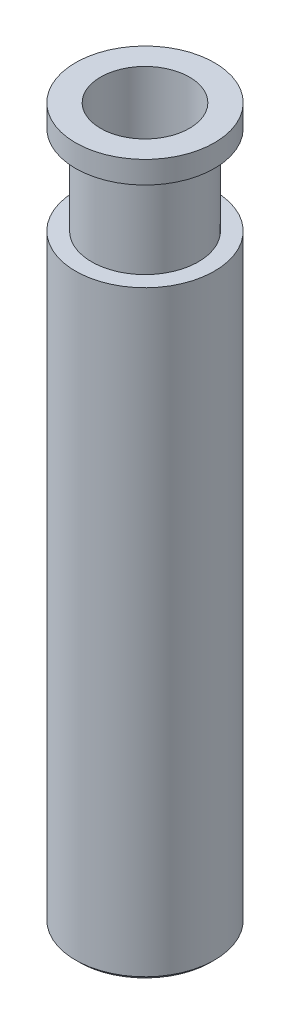
from build123d import *

# Parameters (mm, degrees)
SKETCH1_R           = 4.95935
BOSS_EXTRUDE1_DEPTH = 1.5875
SKETCH2_R           = 3.81
BOSS_EXTRUDE2_DEPTH = 6.35
SKETCH3_R           = 4.95935
BOSS_EXTRUDE4_DEPTH = 42.8625
CHAMFER1_SIZE       = 0.254
SKETCH4_R           = 3.175
CUT_EXTRUDE1_DEPTH  = 7.9375


with BuildPart() as part:
    # Sketch1 → Boss-Extrude1 (new body)
    with BuildSketch(Plane(origin=(0, 0, 0), x_dir=(1, 0, 0), z_dir=(0, 1, 0))):
        Circle(SKETCH1_R)
    extrude(amount=-BOSS_EXTRUDE1_DEPTH)

    # Sketch2 → Boss-Extrude2 (add)
    with BuildSketch(Plane.XZ.offset(1.5875)):
        Circle(SKETCH2_R)
    extrude(amount=BOSS_EXTRUDE2_DEPTH)

    # Sketch3 → Boss-Extrude4 (add)
    with BuildSketch(Plane.XZ.offset(7.9375)):
        Circle(SKETCH3_R)
    extrude(amount=BOSS_EXTRUDE4_DEPTH)

    # Chamfer1
    chamfer1_edges = [part.edges().sort_by_distance(p)[0] for p in [
        (-4.95935, -50.8, 0),
    ]]
    chamfer(chamfer1_edges, length=CHAMFER1_SIZE)

    # Sketch4 → Cut-Extrude1 (cut)
    with BuildSketch(Plane(origin=(0, 0, 0), x_dir=(1, 0, 0), z_dir=(0, 1, 0))):
        Circle(SKETCH4_R)
    extrude(amount=-CUT_EXTRUDE1_DEPTH, mode=Mode.SUBTRACT)


solid = part.part
